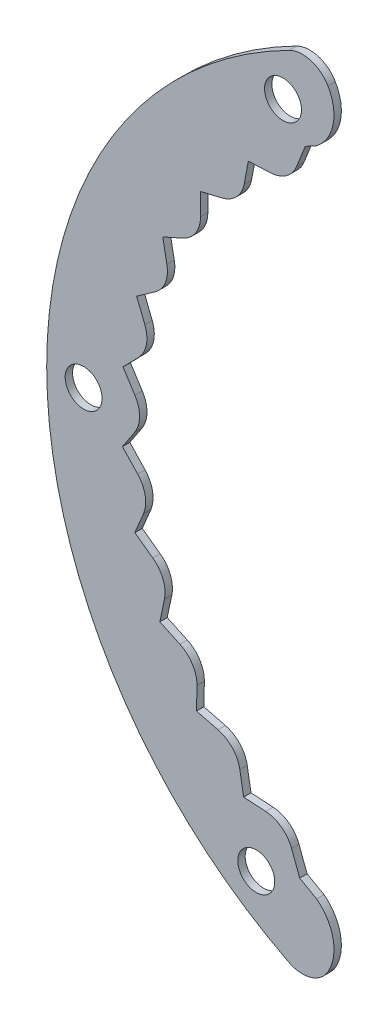
from build123d import *

# Parameters (mm, degrees)
IZIM1_R                     = 2.5
Y_KSEKLIK_EKSTR_ZYON1_DEPTH = 1
SCALE1_SCALE                = 0.5


with BuildPart() as part:
    # Çizim1 → Yükseklik-Ekstrüzyon1 (new body)
    with BuildSketch(Plane.XY):
        with BuildLine():
            Line((-23.446136356, -44.161959762), (-25.73775467, -42.866863479))
            Line((-25.73775467, -42.866863479), (-26.834295942, -39.938466016))
            ThreePointArc((-26.834295942, -39.938466016), (-28.201527977, -38.125336415), (-30.335428898, -37.348658075))
            Line((-30.335428898, -37.348658075), (-33.334907776, -37.164700371))
            Line((-33.334907776, -37.164700371), (-33.842709051, -34.202800331))
            ThreePointArc((-33.842709051, -34.202800331), (-34.84597704, -32.165592505), (-36.7965457, -31.002818113))
            Line((-36.7965457, -31.002818113), (-39.708425324, -30.260072511))
            Line((-39.708425324, -30.260072511), (-39.652227319, -27.255483394))
            ThreePointArc((-39.652227319, -27.255483394), (-40.255989993, -25.066366444), (-41.954126526, -23.558687864))
            Line((-41.954126526, -23.558687864), (-44.675252109, -22.283466496))
            Line((-44.675252109, -22.283466496), (-44.057045667, -19.342627369))
            ThreePointArc((-44.057045667, -19.342627369), (-44.239914432, -17.079151855), (-45.625461503, -15.279979352))
            Line((-45.625461503, -15.279979352), (-48.059435816, -13.517457571))
            Line((-48.059435816, -13.517457571), (-46.901121207, -10.744549126))
            ThreePointArc((-46.901121207, -10.744549126), (-46.656617846, -8.486899797), (-47.680491761, -6.459969953))
            Line((-47.680491761, -6.459969953), (-49.741090048, -4.272585973))
            Line((-49.741090048, -4.272585973), (-48.083701146, -1.765839874))
            ThreePointArc((-48.083701146, -1.765839874), (-47.420487313, 0.406004917), (-48.046416828, 2.588887101))
            Line((-48.046416828, 2.588887101), (-49.660641368, 5.123644113))
            Line((-49.660641368, 5.123644113), (-47.562892001, 7.275425136))
            ThreePointArc((-47.562892001, 7.275425136), (-46.504462376, 9.284526705), (-46.710273625, 11.546031539))
            Line((-46.710273625, 11.546031539), (-47.82093971, 14.338366552))
            Line((-47.82093971, 14.338366552), (-45.357143694, 16.058954583))
            ThreePointArc((-45.357143694, 16.058954583), (-43.940993675, 17.834139505), (-43.719395692, 20.094152054))
            Line((-43.719395692, 20.094152054), (-44.287157421, 23.045145208))
            Line((-44.287157421, 23.045145208), (-41.54459596, 24.273587558))
            ThreePointArc((-41.54459596, 24.273587558), (-39.820893366, 25.751969023), (-39.17973637, 27.930427214))
            Line((-39.17973637, 27.930427214), (-39.184480502, 30.935538106))
            Line((-39.184480502, 30.935538106), (-36.260310201, 31.628316593))
            ThreePointArc((-36.260310201, 31.628316593), (-34.290118058, 32.757522199), (-33.252115355, 34.777253066))
            Line((-33.252115355, 34.777253066), (-32.693673826, 37.730024144))
            Line((-32.693673826, 37.730024144), (-29.691484877, 37.862596744))
            ThreePointArc((-29.691484877, 37.862596744), (-27.544598222, 38.602623821), (-26.146521576, 40.39207739))
            Line((-26.146521576, 40.39207739), (-25, 43.301270189))
            ThreePointArc((-25, 43.301270189), (-24.226890609, 43.73851588), (-23.446136356, 44.161959762))
            ThreePointArc((-23.446136356, 44.161959762), (-21.212806241, 47.755648425), (-21.906244367, 51.929556087))
            ThreePointArc((-21.906244367, 51.929556087), (-24.232021318, 53.76021953), (-27.179564099, 53.490852446))
            ThreePointArc((-27.179564099, 53.490852446), (-59.999999835, 0.004450967), (-27.1875, -53.486819346))
            Line((-27.1875, -53.486819346), (-27.179564099, -53.490852446))
            ThreePointArc((-27.179564099, -53.490852446), (-24.232021318, -53.76021953), (-21.906244367, -51.929556087))
            ThreePointArc((-21.906244367, -51.929556087), (-21.212806241, -47.755648425), (-23.446136356, -44.161959762))
        make_face()
        with Locations((-31.620079453, -45.001895242)):
            Circle(IZIM1_R, mode=Mode.SUBTRACT)
        with Locations((-55, 0)):
            Circle(IZIM1_R, mode=Mode.SUBTRACT)
        with Locations((-28.000624989, 47.338831842)):
            Circle(IZIM1_R, mode=Mode.SUBTRACT)
    extrude(amount=Y_KSEKLIK_EKSTR_ZYON1_DEPTH)


with BuildPart() as part_1:
    # Scale1: scaled about (-43.563815172, 0.008171627, 0.5)
    add(part.part.scale(SCALE1_SCALE).moved(Location((-21.781907586, 0.004085814, 0.25))))


solid = part_1.part
